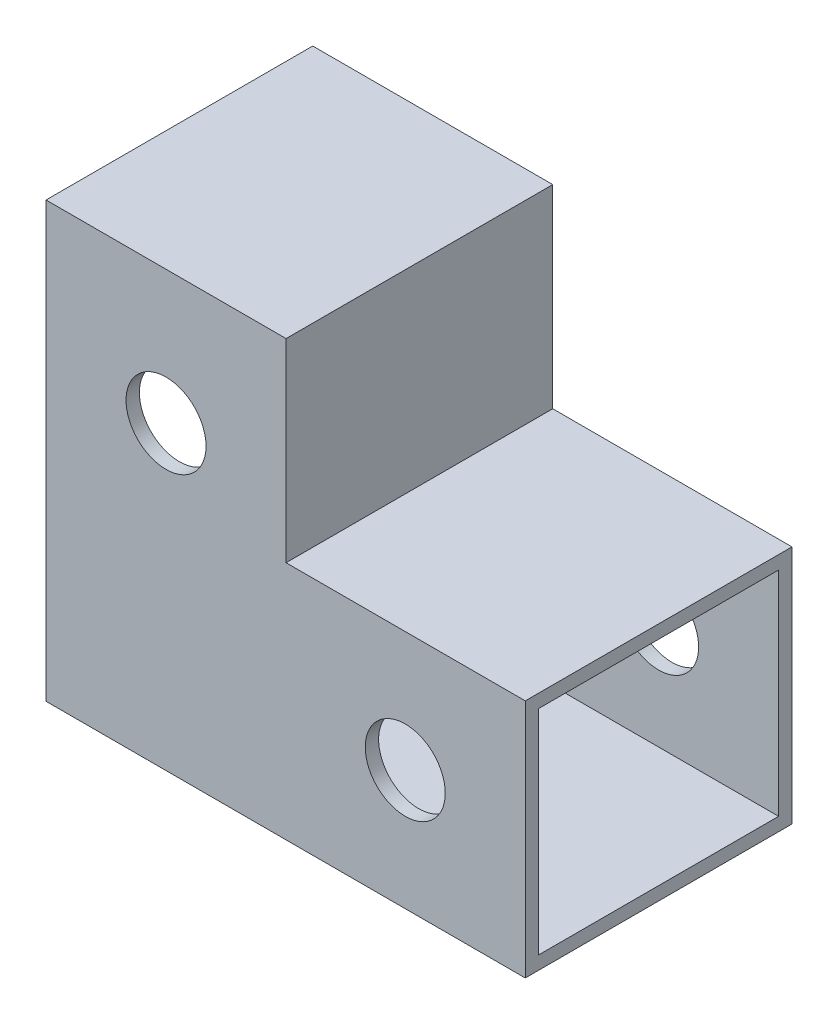
from build123d import *

# Parameters (mm, degrees)
SKETCH4_R           = 3
BOSS_EXTRUDE1_DEPTH = 20
SKETCH5_W           = 18
SKETCH5_H           = 16
CUT_EXTRUDE3_DEPTH  = 36.94
SKETCH6_W           = 18
SKETCH6_H           = 14.56
CUT_EXTRUDE4_DEPTH  = 17


with BuildPart() as part:
    # Sketch4 → Boss-Extrude1 (new body)
    with BuildSketch(Plane.XY):
        Polygon((-8.94, 9), (-8.94, 23.56), (-26.94, 23.56), (-26.94, -9), (9, -9), (9, 9), align=None)
        Circle(SKETCH4_R, mode=Mode.SUBTRACT)
        with Locations((-17.94, 13.56)):
            Circle(SKETCH4_R, mode=Mode.SUBTRACT)
    extrude(amount=BOSS_EXTRUDE1_DEPTH)

    # Sketch5 → Cut-Extrude3 (cut, through all)
    with BuildSketch(Plane(origin=(9, 0, 0), x_dir=(0, 0, -1), z_dir=(1, 0, 0))):
        with Locations((-10, 0)):
            Rectangle(SKETCH5_W, SKETCH5_H)
    extrude(amount=-CUT_EXTRUDE3_DEPTH, mode=Mode.SUBTRACT)

    # Sketch6 → Cut-Extrude4 (cut)
    with BuildSketch(Plane.ZY.offset(26.94)):
        with Locations((10, 15.28)):
            Rectangle(SKETCH6_W, SKETCH6_H)
    extrude(amount=-CUT_EXTRUDE4_DEPTH, mode=Mode.SUBTRACT)


solid = part.part
